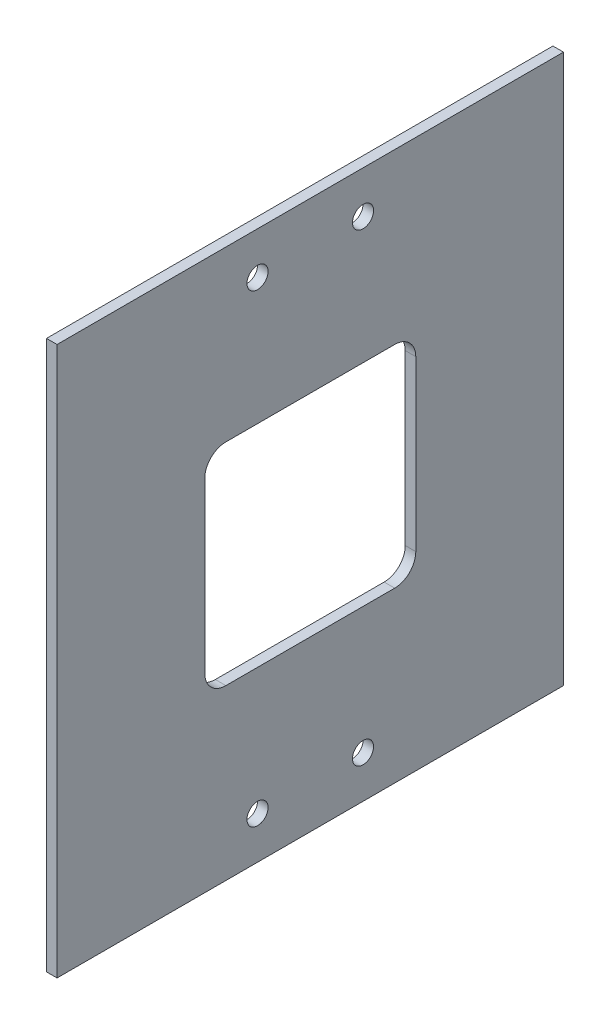
from build123d import *

# Parameters (mm, degrees)
SKETCH1_W           = 152.4
SKETCH1_H           = 165.1
BOSS_EXTRUDE1_DEPTH = 3.175
CUT_EXTRUDE1_DEPTH  = 4.175
SKETCH3_R           = 3.175
CUT_EXTRUDE2_DEPTH  = 4.175


with BuildPart() as part:
    # Sketch1 → Boss-Extrude1 (new body)
    with BuildSketch(Plane(origin=(0, 0, 0), x_dir=(0, 0, -1), z_dir=(1, 0, 0))):
        with Locations((76.2, 0)):
            Rectangle(SKETCH1_W, SKETCH1_H)
    extrude(amount=BOSS_EXTRUDE1_DEPTH)

    # Sketch2 → Cut-Extrude1 (cut, through all)
    with BuildSketch(Plane.ZY):
        with BuildLine():
            Line((-107.95, 25.4), (-107.95, -25.4))
            ThreePointArc((-107.95, -25.4), (-106.090128061, -29.890128061), (-101.6, -31.75))
            Line((-101.6, -31.75), (-50.8, -31.75))
            ThreePointArc((-50.8, -31.75), (-46.309871939, -29.890128061), (-44.45, -25.4))
            Line((-44.45, -25.4), (-44.45, 25.4))
            ThreePointArc((-44.45, 25.4), (-46.309871939, 29.890128061), (-50.8, 31.75))
            Line((-50.8, 31.75), (-101.6, 31.75))
            ThreePointArc((-101.6, 31.75), (-106.090128061, 29.890128061), (-107.95, 25.4))
        make_face()
    extrude(amount=-CUT_EXTRUDE1_DEPTH, mode=Mode.SUBTRACT)

    # Sketch3 → Cut-Extrude2 (cut, through all)
    with BuildSketch(Plane.ZY):
        with Locations((-60.325, 69.85)):
            Circle(SKETCH3_R)
        with Locations((-92.075, 69.85)):
            Circle(SKETCH3_R)
        with Locations((-92.075, -69.85)):
            Circle(SKETCH3_R)
        with Locations((-60.325, -69.85)):
            Circle(SKETCH3_R)
    extrude(amount=-CUT_EXTRUDE2_DEPTH, mode=Mode.SUBTRACT)


solid = part.part
